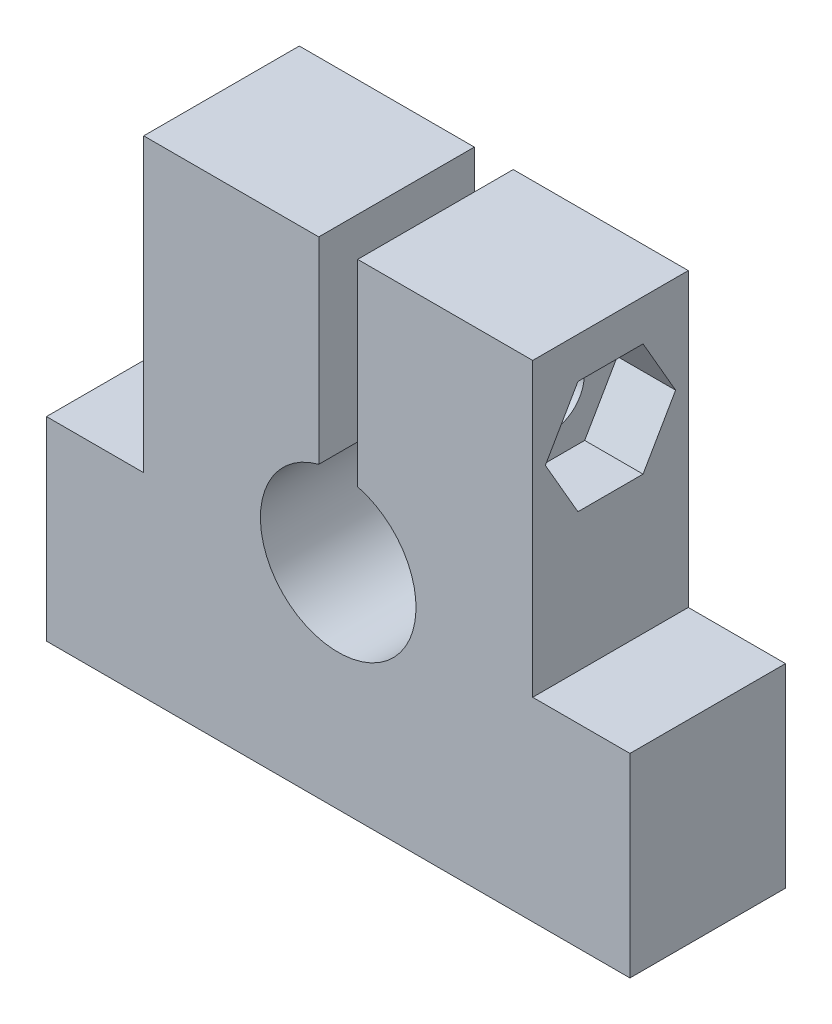
from build123d import *

# Parameters (mm, degrees)
EXTRUDE_1_DEPTH     = 8
CUT_EXTRUDE_1_DEPTH = 9
SKETCH_3_R          = 1.65
CUT_EXTRUDE_2_DEPTH = 26
SKETCH_4_R          = 3
CUT_EXTRUDE_3_DEPTH = 3.3
CUT_EXTRUDE_4_DEPTH = 3


with BuildPart() as part:
    # 草图1 → 凸台-拉伸1 (new body)
    with BuildSketch(Plane.XY):
        Polygon((-10, 25), (10, 25), (10, 10), (15, 10), (15, 0), (-15, 0), (-15, 10), (-10, 10), align=None)
    extrude(amount=EXTRUDE_1_DEPTH)

    # 草图2 → 切除-拉伸1 (cut, through all)
    with BuildSketch(Plane.XY.offset(8)):
        with BuildLine():
            Line((-1, 25), (1, 25))
            Line((1, 25), (1, 14.872983346))
            ThreePointArc((1, 14.872983346), (0, 7), (-1, 14.872983346))
            Line((-1, 14.872983346), (-1, 25))
        make_face()
    extrude(amount=-CUT_EXTRUDE_1_DEPTH, mode=Mode.SUBTRACT)

    # 草图3 → 切除-拉伸2 (cut, through all)
    with BuildSketch(Plane.ZY.offset(10)):
        with Locations((4, 20)):
            Circle(SKETCH_3_R)
    extrude(amount=-CUT_EXTRUDE_2_DEPTH, mode=Mode.SUBTRACT)

    # 草图4 → 切除-拉伸3 (cut)
    with BuildSketch(Plane.ZY.offset(10)):
        with Locations((4, 20)):
            Circle(SKETCH_4_R)
    extrude(amount=-CUT_EXTRUDE_3_DEPTH, mode=Mode.SUBTRACT)

    # 草图5 → 切除-拉伸4 (cut)
    with BuildSketch(Plane(origin=(10, 0, 0), x_dir=(0, 0, -1), z_dir=(1, 0, 0))):
        Polygon((-7.348631561, 20), (-5.674315781, 17.1), (-2.325684219, 17.1), (-0.651368439, 20), (-2.325684219, 22.9), (-5.674315781, 22.9), align=None)
    extrude(amount=-CUT_EXTRUDE_4_DEPTH, mode=Mode.SUBTRACT)


solid = part.part
